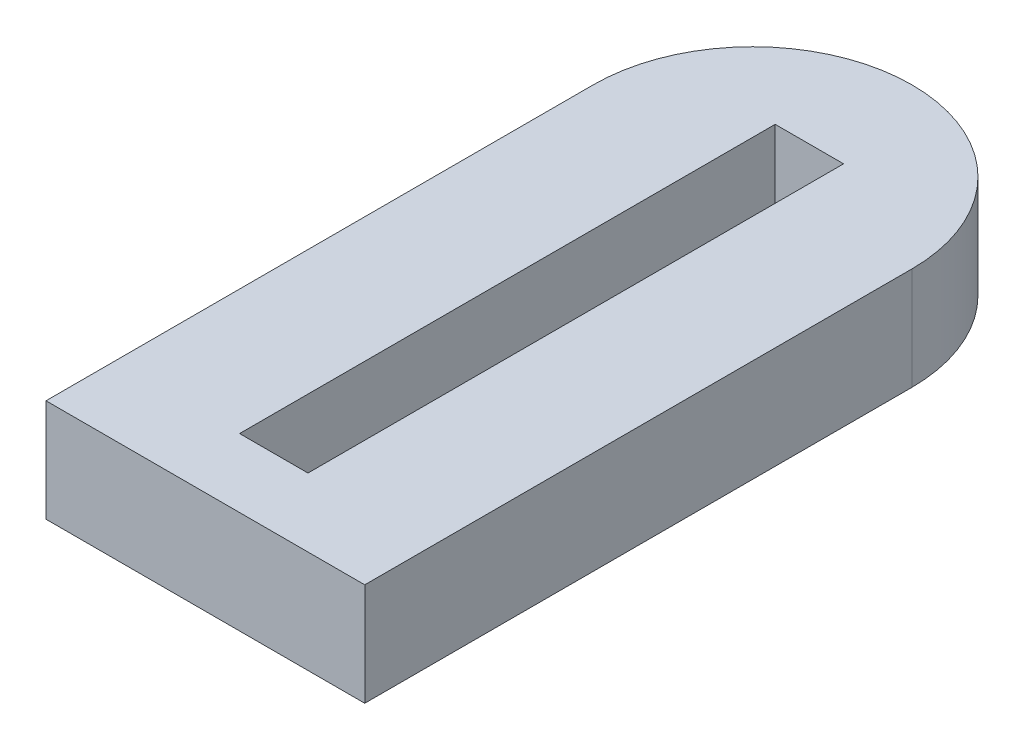
from build123d import *

# Parameters (mm, degrees)
SKETCH1_W           = 12.7
SKETCH1_H           = 99.441
BOSS_EXTRUDE1_DEPTH = 19.05


with BuildPart() as part:
    # Sketch1 → Boss-Extrude1 (new body)
    with BuildSketch(Plane(origin=(0, 0, 0), x_dir=(1, 0, 0), z_dir=(0, 1, 0))):
        with BuildLine():
            Line((-59.182, 0), (0, 0))
            Line((0, 0), (0, 101.6))
            ThreePointArc((0, 101.6), (-29.591, 131.191), (-59.182, 101.6))
            Line((-59.182, 101.6), (-59.182, 0))
        make_face()
        with Locations((-29.591, 62.4205)):
            Rectangle(SKETCH1_W, SKETCH1_H, mode=Mode.SUBTRACT)
    extrude(amount=BOSS_EXTRUDE1_DEPTH)


solid = part.part
